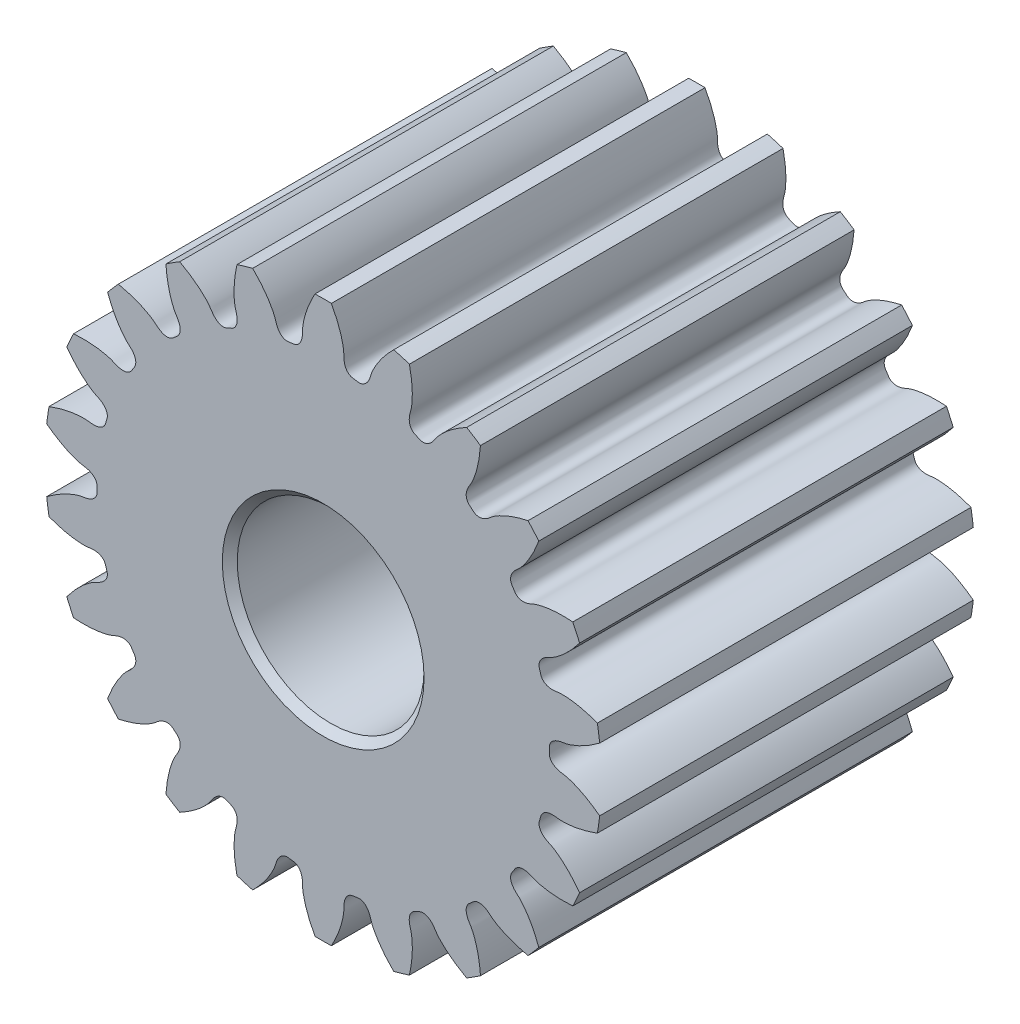
from build123d import *

# Parameters (mm, degrees)
SKETCHREVOLVESUN_FIXED01_W       = 12.7
SKETCHREVOLVESUN_FIXED01_H       = 9.458817834
TOOTHEXTRUDECUTSUN_FIXED01_DEPTH = 6.35
PATTERNSUN_FIXED01_COUNT         = 22


with BuildPart() as part:
    # SketchRevolveSun_Fixed01 → Sun_Fixed01 (revolve)
    with BuildSketch(Plane(origin=(0, 0, 0), x_dir=(0, 0, -1), z_dir=(1, 0, 0))):
        with Locations((0, 4.729408917)):
            Rectangle(SKETCHREVOLVESUN_FIXED01_W, SKETCHREVOLVESUN_FIXED01_H)
    revolve(axis=Axis((0, 0, 0), (0, 0, -1)))

    # SketchToothSun_Fixed01 → ToothExtrudeCutSun_Fixed01 (cut, symmetric)
    with BuildSketch(Plane.XY):
        with BuildLine():
            ThreePointArc((9.434557732, 1.09794602), (9.498229575, 0), (9.434557732, -1.09794602))
            add(Edge.make_bspline(
                [(9.434557732, -1.09794602), (9.361139461, -1.041479802), (9.251564274, -0.962036397), (9.104865136, -0.865674051), (9.002071963, -0.802473361), (8.903775308, -0.746019109), (8.81028139, -0.695982058), (8.721880642, -0.652020711), (8.638847261, -0.613782126), (8.561438778, -0.580902612), (8.489895699, -0.553008187), (8.424441023, -0.529716043), (8.365280244, -0.5106328), (8.312599963, -0.495362975), (8.266570904, -0.483485829), (8.227337721, -0.474627846), (8.167580986, -0.462835896), (8.112851519, -0.457162177), (8.06263208, -0.446944267), (8.041261549, -0.442123999), (8.020336855, -0.436835361), (7.999837341, -0.431082514), (7.979743855, -0.424839387), (7.960034378, -0.418080477), (7.940685361, -0.410771234), (7.921671785, -0.402868747), (7.902967931, -0.394319374), (7.884548495, -0.385056806), (7.866390413, -0.374999669), (7.848475639, -0.364048996), (7.83079526, -0.352085723), (7.813355434, -0.33896865), (7.796185615, -0.324533607), (7.779349517, -0.308595062), (7.762958831, -0.290951986), (7.747188928, -0.271400384), (7.732294099, -0.249755221), (7.71861804, -0.225883505), (7.706590874, -0.199748388), (7.696710531, -0.171456074), (7.689477831, -0.141302061), (7.685665, -0.111919502), (7.684004894, -0.064667992), (7.686272459, 0), (7.684004894, 0.064667992), (7.685665, 0.111919502), (7.689477831, 0.141302061), (7.696710531, 0.171456074), (7.706590874, 0.199748388), (7.71861804, 0.225883505), (7.732294099, 0.249755221), (7.747188928, 0.271400384), (7.762958831, 0.290951986), (7.779349517, 0.308595062), (7.796185615, 0.324533607), (7.813355434, 0.33896865), (7.83079526, 0.352085723), (7.848475639, 0.364048996), (7.866390413, 0.374999669), (7.884548495, 0.385056806), (7.902967931, 0.394319374), (7.921671785, 0.402868747), (7.940685361, 0.410771234), (7.960034378, 0.418080477), (7.979743855, 0.424839387), (7.999837341, 0.431082514), (8.020336855, 0.436835361), (8.041261549, 0.442123999), (8.06263208, 0.446944267), (8.112851519, 0.457162177), (8.167580986, 0.462835896), (8.227337721, 0.474627846), (8.266570904, 0.483485829), (8.312599963, 0.495362975), (8.365280244, 0.5106328), (8.424441023, 0.529716043), (8.489895699, 0.553008187), (8.561438778, 0.580902612), (8.638847261, 0.613782126), (8.721880642, 0.652020711), (8.81028139, 0.695982058), (8.903775308, 0.746019109), (9.002071963, 0.802473361), (9.104865136, 0.865674051), (9.251564274, 0.962036397), (9.361139461, 1.041479802), (9.434557732, 1.09794602)],
                knots=[0, 0, 0, 0, 0.063462617, 0.092688822, 0.120244958, 0.146131025, 0.170347024, 0.192892954, 0.213768815, 0.232974607, 0.25051033, 0.266375985, 0.280571571, 0.293097088, 0.303952536, 0.313137916, 0.320653227, 0.345676389, 0.3507593, 0.355760281, 0.360686414, 0.365545723, 0.370347327, 0.375101604, 0.379820382, 0.384517156, 0.389207322, 0.393908432, 0.398640446, 0.403425963, 0.40829039, 0.41326197, 0.418371582, 0.423652136, 0.429137392, 0.434859943, 0.440848149, 0.447121936, 0.453687692, 0.460533012, 0.467622686, 0.474897737, 0.480791834, 0.5, 0.519208166, 0.525102263, 0.532377314, 0.539466988, 0.546312308, 0.552878064, 0.559151851, 0.565140057, 0.570862608, 0.576347864, 0.581628418, 0.58673803, 0.59170961, 0.596574037, 0.601359554, 0.606091568, 0.610792678, 0.615482844, 0.620179618, 0.624898396, 0.629652673, 0.634454277, 0.639313586, 0.644239719, 0.6492407, 0.654323611, 0.679346773, 0.686862084, 0.696047464, 0.706902912, 0.719428429, 0.733624015, 0.74948967, 0.767025393, 0.786231185, 0.807107046, 0.829652976, 0.853868975, 0.879755042, 0.907311178, 0.936537383, 1, 1, 1, 1], degree=3))
        make_face()
    toothextrudecutsun_fixed01 = extrude(amount=TOOTHEXTRUDECUTSUN_FIXED01_DEPTH, both=True, mode=Mode.SUBTRACT)

    # PatternSun_Fixed01: ToothExtrudeCutSun_Fixed01 ×22 about axis
    patternsun_fixed01_axis = Axis((0, 0, 55), (0, 0, -1))
    for i in range(1, PATTERNSUN_FIXED01_COUNT):
        add(toothextrudecutsun_fixed01.rotate(patternsun_fixed01_axis, i * 360 / PATTERNSUN_FIXED01_COUNT), mode=Mode.SUBTRACT)

    # BoreRevolveSketch → BoreRevolveCut (revolve, cut)
    with BuildSketch(Plane(origin=(0, 0, 0), x_dir=(0, 0, -1), z_dir=(1, 0, 0))):
        Polygon((-6.35, 0), (6.35, 0), (6.35, 3.429), (6.096, 3.175), (-6.096, 3.175), (-6.35, 3.429), align=None)
    revolve(axis=Axis((0, 0, 0), (0, 0, -1)), mode=Mode.SUBTRACT)


solid = part.part
